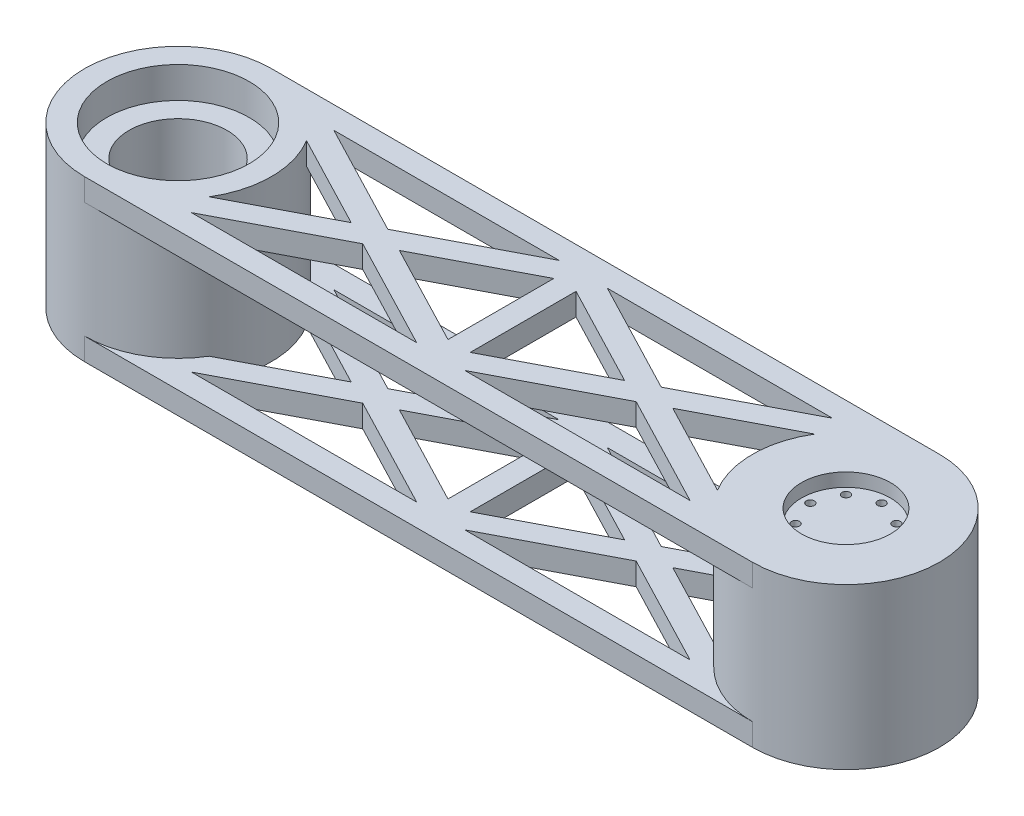
from build123d import *

# Parameters (mm, degrees)
SKETCH_1_R          = 21
SKETCH_1_R_2        = 10
EXTRUDE_1_DEPTH     = 36
SKETCH_1_R_3        = 16
EXTRUDE_1_2_DEPTH   = 36
SKETCH_2_W          = 150
SKETCH_2_H          = 5
EXTRUDE_3_DEPTH     = 5
SKETCH_3_W          = 150
SKETCH_3_H          = 5
EXTRUDE_4_DEPTH     = 5
EXTRUDE_5_DEPTH     = 5
EXTRUDE_START       = -3
SKETCH_7_R          = 16
EXTRUDE_7_DEPTH     = 30
SKETCH_8_R          = 0.9
CUT_EXTRUDE_1_DEPTH = 8
EXTRUDE_START_2     = -7
SKETCH_10_R         = 18.243216987
SKETCH_10_R_2       = 11
EXTRUDE_8_DEPTH     = 22


with BuildPart() as part:
    # 스케치1 → 보스-돌출1 (new body)
    with BuildSketch(Plane(origin=(0, 0, 0), x_dir=(1, 0, 0), z_dir=(0, 1, 0))):
        with Locations((68.910572273, -5.294054995)):
            Circle(SKETCH_1_R)
        with Locations((68.910572273, -5.294054995)):
            Circle(SKETCH_1_R_2, mode=Mode.SUBTRACT)
    extrude(amount=EXTRUDE_1_DEPTH)



with BuildPart() as body_2:
    # 스케치1 → Extrude 1 2 (new body)
    with BuildSketch(Plane(origin=(0, 0, 0), x_dir=(1, 0, 0), z_dir=(0, 1, 0))):
        with Locations((-81.089427727, -5.294054995)):
            Circle(SKETCH_1_R)
        with Locations((-81.089427727, -5.294054995)):
            Circle(SKETCH_1_R_3, mode=Mode.SUBTRACT)
    extrude(amount=EXTRUDE_1_2_DEPTH)


with BuildPart() as part_1:
    add(part.part)

    add(body_2.part)  # 보스-돌출3 merges body 2
    # 스케치2 → 보스-돌출3 (add)
    with BuildSketch(Plane(origin=(0, 36, 0), x_dir=(1, 0, 0), z_dir=(0, 1, 0))):
        with Locations((-6.089427727, -23.794054995)):
            Rectangle(SKETCH_2_W, SKETCH_2_H)
        with Locations((-6.089427727, 13.205945005)):
            Rectangle(SKETCH_2_W, SKETCH_2_H)
    extrude(amount=-EXTRUDE_3_DEPTH)

    # 스케치3 → 보스-돌출4 (add)
    with BuildSketch(Plane.XZ):
        with Locations((-6.089427727, -13.205945005)):
            Rectangle(SKETCH_3_W, SKETCH_3_H)
        with Locations((-6.089427727, 23.794054995)):
            Rectangle(SKETCH_3_W, SKETCH_3_H)
    extrude(amount=-EXTRUDE_4_DEPTH)

    # 스케치4 → 보스-돌출5 (add)
    with BuildSketch(Plane.XZ):
        Polygon((-36.788692473, 8.113223678), (-7.244877213, 23.511020598), (-6.089427727, 21.294054995), (-4.933978242, 23.511020598), (24.609837018, 8.113223678), (54.153652279, 23.511020598), (56.46455125, 19.077089392), (30.018987378, 5.294054995), (56.46455125, -8.488979402), (54.153652279, -12.922910608), (24.609837018, 2.474886312), (-4.933978242, -12.922910608), (-7.244877213, -12.922910608), (-36.788692473, 2.474886312), (-66.332507733, -12.922910608), (-68.643406704, -8.488979402), (-42.197842833, 5.294054995), (-68.643406704, 19.077089392), (-66.332507733, 23.511020598), align=None)
        Polygon((-31.379542113, 5.294054995), (-8.589427727, -6.583813521), (-8.589427727, 17.17192351), align=None, mode=Mode.SUBTRACT)
        Polygon((-3.589427727, -6.583813521), (19.200686659, 5.294054995), (-3.589427727, 17.17192351), align=None, mode=Mode.SUBTRACT)
    extrude_5 = extrude(amount=-EXTRUDE_5_DEPTH)

    # 스케치7 → 보스-돌출7 (add)
    with BuildSketch(Plane(origin=(0, 36, 0), x_dir=(1, 0, 0), z_dir=(0, 1, 0)).offset(EXTRUDE_START)):
        with Locations((68.910572273, -5.294054995)):
            Circle(SKETCH_7_R)
    extrude(amount=-EXTRUDE_7_DEPTH)

    # 스케치8 → 컷-돌출1 (cut)
    with BuildSketch(Plane(origin=(0, 33, 0), x_dir=(1, 0, 0), z_dir=(0, 1, 0))):
        with Locations((76.910572273, -5.294054995)):
            Circle(SKETCH_8_R)
        with Locations((68.910572273, 2.705945005)):
            Circle(SKETCH_8_R)
        with Locations((74.567426522, 0.362799255)):
            Circle(SKETCH_8_R)
        with Locations((63.253718023, 0.362799255)):
            Circle(SKETCH_8_R)
        with Locations((60.910572273, -5.294054995)):
            Circle(SKETCH_8_R)
        with Locations((68.910572273, -13.294054995)):
            Circle(SKETCH_8_R)
        with Locations((63.253718023, -10.950909244)):
            Circle(SKETCH_8_R)
        with Locations((74.567426522, -10.950909244)):
            Circle(SKETCH_8_R)
    cut_extrude_1 = extrude(amount=-CUT_EXTRUDE_1_DEPTH, mode=Mode.SUBTRACT)

    # 대칭 복사1: 컷-돌출1 across plane
    add(cut_extrude_1.mirror(Plane.ZX.offset(18)), mode=Mode.SUBTRACT)

    # 대칭 복사2: 보스-돌출5 across plane
    add(extrude_5.mirror(Plane.ZX.offset(18)))

    # 스케치10 → 보스-돌출8 (add)
    with BuildSketch(Plane(origin=(0, 36, 0), x_dir=(1, 0, 0), z_dir=(0, 1, 0)).offset(EXTRUDE_START_2)):
        with Locations((-81.089427727, -5.294054995)):
            Circle(SKETCH_10_R)
        with Locations((-81.089427727, -5.294054995)):
            Circle(SKETCH_10_R_2, mode=Mode.SUBTRACT)
    extrude(amount=-EXTRUDE_8_DEPTH)


solid = part_1.part
